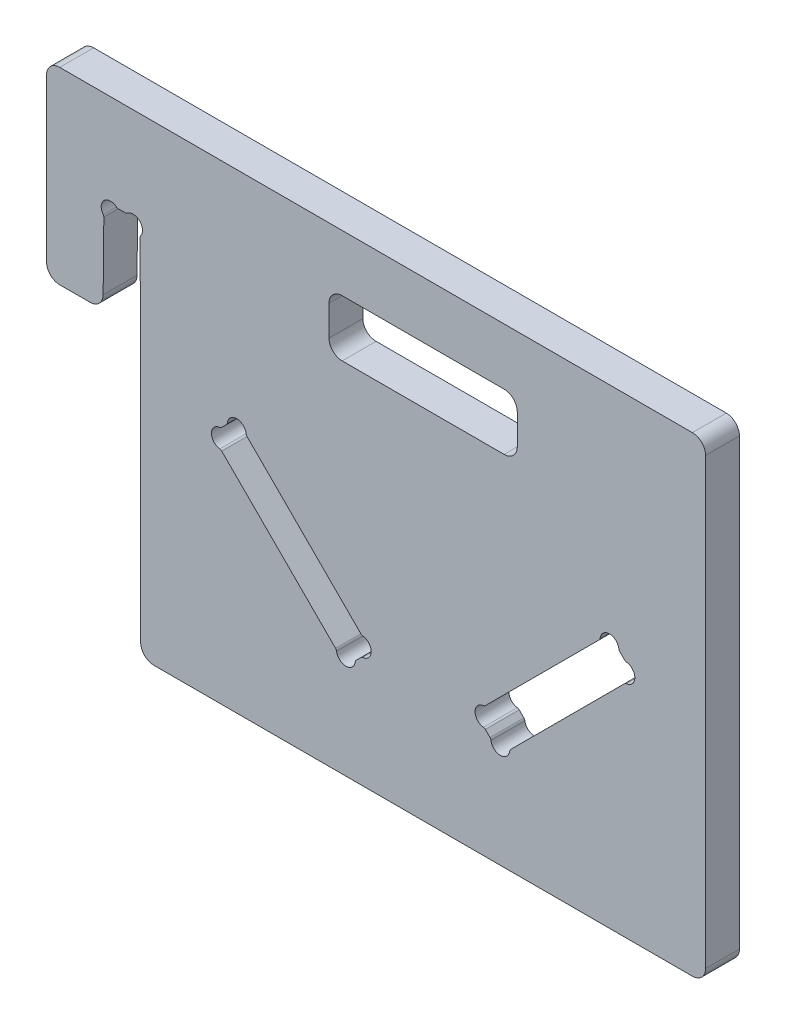
from build123d import *

# Parameters (mm, degrees)
BOSS_EXTRU_2_DEPTH      = 18
ESQUISSE1_W             = 100
ESQUISSE1_H             = 30
ENL_V_MAT_EXTRU_1_DEPTH = 19
CONG_1_R                = 7


with BuildPart() as part:
    # Esquisse2 → Boss.-Extru.2 (new body)
    with BuildSketch(Plane.XY):
        Polygon((0, 0), (350, 0), (350, -250), (50, -250), (50, -100), (0, -100), align=None)
    extrude(amount=BOSS_EXTRU_2_DEPTH)

    # Esquisse1 → Enlèv. mat.-Extru.1 (cut, through all)
    with BuildSketch(Plane.XY):
        with BuildLine():
            Line((106.489567957, -120.054539114), (166.945460886, -180.510432043))
            ThreePointArc((166.945460886, -180.510432043), (167.433604863, -180.857617354), (168.008646739, -181.025394064))
            ThreePointArc((168.008646739, -181.025394064), (172.426406871, -185.991378029), (168.008646739, -190.957361993))
            ThreePointArc((168.008646739, -190.957361993), (167.433604863, -191.125138703), (166.945460886, -191.472324014))
            Line((166.945460886, -191.472324014), (164.472324014, -193.945460886))
            ThreePointArc((164.472324014, -193.945460886), (164.125138703, -194.433604863), (163.957361993, -195.008646739))
            ThreePointArc((163.957361993, -195.008646739), (158.991378029, -199.426406871), (154.025394064, -195.008646739))
            ThreePointArc((154.025394064, -195.008646739), (153.857617354, -194.433604863), (153.510432043, -193.945460886))
            Line((153.510432043, -193.945460886), (93.054539114, -133.489567957))
            ThreePointArc((93.054539114, -133.489567957), (92.566395137, -133.142382646), (91.991353261, -132.974605936))
            ThreePointArc((91.991353261, -132.974605936), (87.573593129, -128.008621971), (91.991353261, -123.042638007))
            ThreePointArc((91.991353261, -123.042638007), (92.566395137, -122.874861297), (93.054539114, -122.527675986))
            Line((93.054539114, -122.527675986), (95.527675986, -120.054539114))
            ThreePointArc((95.527675986, -120.054539114), (95.874861297, -119.566395137), (96.042638007, -118.991353261))
            ThreePointArc((96.042638007, -118.991353261), (101.008621971, -114.573593129), (105.974605936, -118.991353261))
            ThreePointArc((105.974605936, -118.991353261), (106.142382646, -119.566395137), (106.489567957, -120.054539114))
        make_face()
        with BuildLine():
            Line((50, -100), (30, -100))
            Line((30, -100), (30.424047381, -57.1712145))
            ThreePointArc((30.424047381, -57.1712145), (30.332595572, -56.586679793), (30.056564564, -56.06337191))
            ThreePointArc((30.056564564, -56.06337191), (30.532330845, -49.467962139), (37.135309084, -49.11234721))
            ThreePointArc((37.135309084, -49.11234721), (37.660561143, -49.400327171), (38.251228148, -49.5))
            Line((38.251228148, -49.5), (41.748771852, -49.5))
            ThreePointArc((41.748771852, -49.5), (42.339438857, -49.400327171), (42.864690916, -49.11234721))
            ThreePointArc((42.864690916, -49.11234721), (49.467669155, -49.467962139), (49.943435436, -56.06337191))
            ThreePointArc((49.943435436, -56.06337191), (49.667404428, -56.586679793), (49.575952619, -57.1712145))
            Line((49.575952619, -57.1712145), (50, -100))
        make_face()
        with Locations((200, -45)):
            Rectangle(ESQUISSE1_W, ESQUISSE1_H)
        with BuildLine():
            Line((304.472324014, -120.054539114), (306.945460886, -122.527675986))
            ThreePointArc((306.945460886, -122.527675986), (307.433604863, -122.874861297), (308.008646739, -123.042638007))
            ThreePointArc((308.008646739, -123.042638007), (312.426406871, -128.008621971), (308.008646739, -132.974605936))
            ThreePointArc((308.008646739, -132.974605936), (307.433604863, -133.142382646), (306.945460886, -133.489567957))
            Line((306.945460886, -133.489567957), (246.489567957, -193.945460886))
            ThreePointArc((246.489567957, -193.945460886), (246.142382646, -194.433604863), (245.974605936, -195.008646739))
            ThreePointArc((245.974605936, -195.008646739), (241.008621971, -199.426406871), (236.042638007, -195.008646739))
            ThreePointArc((236.042638007, -195.008646739), (235.874861297, -194.433604863), (235.527675986, -193.945460886))
            Line((235.527675986, -193.945460886), (233.054539114, -191.472324014))
            ThreePointArc((233.054539114, -191.472324014), (232.566395137, -191.125138703), (231.991353261, -190.957361993))
            ThreePointArc((231.991353261, -190.957361993), (227.573593129, -185.991378029), (231.991353261, -181.025394064))
            ThreePointArc((231.991353261, -181.025394064), (232.566395137, -180.857617354), (233.054539114, -180.510432043))
            Line((233.054539114, -180.510432043), (293.510432043, -120.054539114))
            ThreePointArc((293.510432043, -120.054539114), (293.857617354, -119.566395137), (294.025394064, -118.991353261))
            ThreePointArc((294.025394064, -118.991353261), (298.991378029, -114.573593129), (303.957361993, -118.991353261))
            ThreePointArc((303.957361993, -118.991353261), (304.125138703, -119.566395137), (304.472324014, -120.054539114))
        make_face()
    extrude(amount=ENL_V_MAT_EXTRU_1_DEPTH, mode=Mode.SUBTRACT)

    # Congé1
    cong_1_edges = [part.edges().sort_by_distance(p)[0] for p in [
        (0, 0, 9),
        (350, 0, 9),
        (350, -250, 9),
        (50, -250, 9),
        (0, -100, 9),
        (150, -30, 9),
        (150, -60, 9),
        (250, -60, 9),
        (250, -30, 9),
        (30, -100, 9),
    ]]
    fillet(cong_1_edges, radius=CONG_1_R)


solid = part.part
